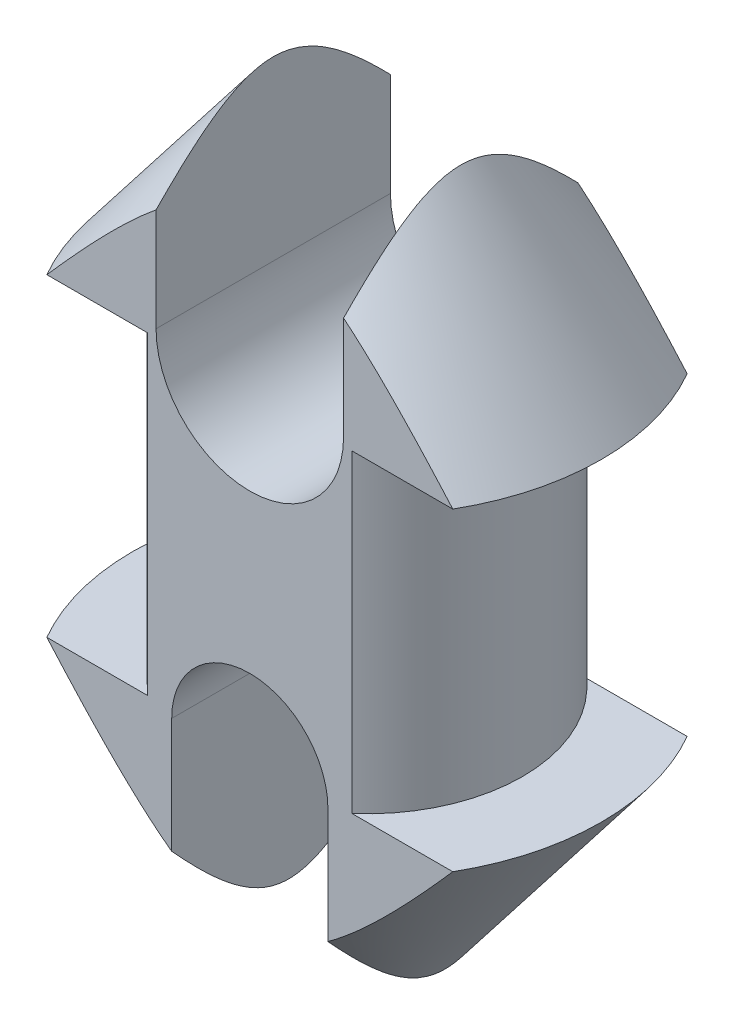
from build123d import *

# Parameters (mm, degrees)
ESBO_O2_OUTSIDE_W          = 45.13
ESBO_O2_OUTSIDE_H          = 45.13
ESBO_O2_OUTSIDE_W_2        = 30
ESBO_O2_OUTSIDE_H_2        = 15
CORTE_EXTRUS_O1_DEPTH      = 26.05
CORTE_EXTRUS_O1_DEPTH_BACK = 26.05
CORTE_EXTRUS_O2_DEPTH      = 16


with BuildPart() as part:
    # Esboço1 one side → Revolução1 (revolve)
    with BuildSketch(Plane.XY):
        with BuildLine():
            ThreePointArc((4, 24.506832295), (2.018355219, 24.913587797), (0, 25.05))
            Line((0, 25.05), (0, -25.05))
            ThreePointArc((0, -25.05), (2.018355219, -24.913587797), (4, -24.506832295))
            Line((4, -24.506832295), (15, -10.05))
            Line((15, -10.05), (9.95, -10.05))
            Line((9.95, -10.05), (9.95, 10.05))
            Line((9.95, 10.05), (15, 10.05))
            Line((15, 10.05), (4, 24.506832295))
        make_face()
    revolve(axis=Axis((0, -25.05, 0), (0, 1, 0)))

    # Esboço2 outside → Corte-extrusão1 (cut, two sides)
    with BuildSketch(Plane(origin=(0, 0, 0), x_dir=(1, 0, 0), z_dir=(0, 1, 0))) as corte_extrus_o1_sk:
        Rectangle(ESBO_O2_OUTSIDE_W, ESBO_O2_OUTSIDE_H)
        Rectangle(ESBO_O2_OUTSIDE_W_2, ESBO_O2_OUTSIDE_H_2, mode=Mode.SUBTRACT)
    extrude(amount=CORTE_EXTRUS_O1_DEPTH, mode=Mode.SUBTRACT)
    extrude(corte_extrus_o1_sk.sketch, amount=-CORTE_EXTRUS_O1_DEPTH_BACK, mode=Mode.SUBTRACT)

    # Esboço3 → Corte-extrusão2 (cut, through all)
    with BuildSketch(Plane(origin=(0, 0, -7.5), x_dir=(-1, 0, 0), z_dir=(0, 0, -1))):
        with BuildLine():
            Line((6, 25.05), (6, 10.55))
            ThreePointArc((6, 10.55), (0, 4.55), (-6, 10.55))
            Line((-6, 10.55), (-6, 25.05))
            ThreePointArc((-6, 25.05), (0, 31.05), (6, 25.05))
        make_face()
        with BuildLine():
            Line((-5, -25.05), (-5, -10.55))
            ThreePointArc((-5, -10.55), (0, -5.55), (5, -10.55))
            Line((5, -10.55), (5, -25.05))
            ThreePointArc((5, -25.05), (0, -30.05), (-5, -25.05))
        make_face()
    extrude(amount=-CORTE_EXTRUS_O2_DEPTH, mode=Mode.SUBTRACT)


solid = part.part
